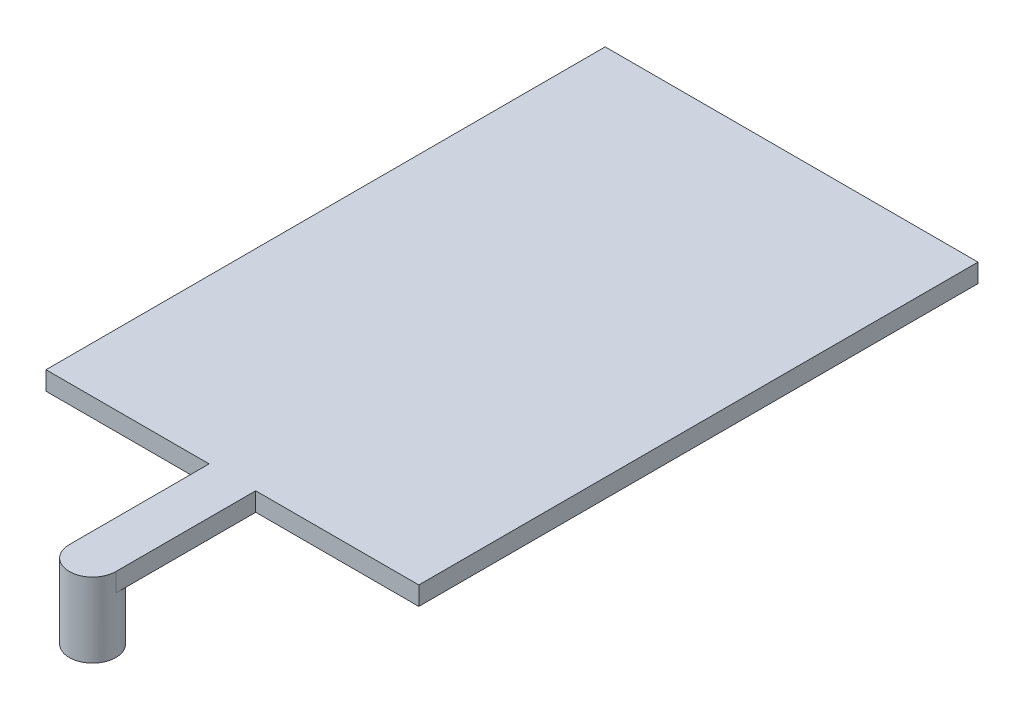
from build123d import *

# Parameters (mm, degrees)
SKETCH_1_W      = 0.25
SKETCH_1_H      = 0.75
EXTRUDE_1_DEPTH = 0.1
SKETCH_2_R      = 0.125
EXTRUDE_2_DEPTH = 0.4


with BuildPart() as part:
    # Эскиз1 → Бобышка-Вытянуть1 (new body)
    with BuildSketch(Plane(origin=(0, 0, 0), x_dir=(1, 0, 0), z_dir=(0, 1, 0))):
        Polygon((-1, -1.5), (-0.125, -1.5), (0.125, -1.5), (1, -1.5), (1, 1.5), (-1, 1.5), align=None)
        with Locations((0, -1.875)):
            Rectangle(SKETCH_1_W, SKETCH_1_H)
    extrude(amount=EXTRUDE_1_DEPTH)

    # Эскиз2 → Бобышка-Вытянуть2 (add)
    with BuildSketch(Plane(origin=(0, 0.1, 0), x_dir=(1, 0, 0), z_dir=(0, 1, 0))):
        with Locations((0, -2.25)):
            Circle(SKETCH_2_R)
    extrude(amount=-EXTRUDE_2_DEPTH)


solid = part.part
